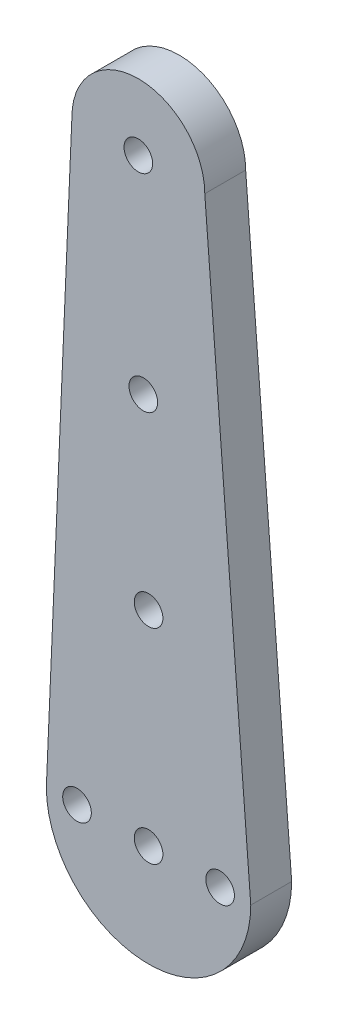
from build123d import *

# Parameters (mm, degrees)
SKETCH1_R           = 1.4
BOSS_EXTRUDE1_DEPTH = 4


with BuildPart() as part:
    # Sketch1 → Boss-Extrude1 (new body)
    with BuildSketch(Plane.XY):
        with BuildLine():
            ThreePointArc((-0.000688459, 65.016091721), (-6.500688459, 71.516091721), (-13.000688459, 65.016091721))
            Line((-13.000688459, 65.016091721), (-15.463628279, 7.853451097))
            Line((-15.463628279, 7.853451097), (-15.500688459, 6.993317296))
            ThreePointArc((-15.500688459, 6.993317296), (-5.500688459, -3.006682704), (4.499311541, 6.993317296))
            Line((4.499311541, 6.993317296), (4.379732895, 8.535158357))
            Line((4.379732895, 8.535158357), (-0.000688459, 65.016091721))
        make_face()
        with Locations((-12.500688459, 6.993317296)):
            Circle(SKETCH1_R, mode=Mode.SUBTRACT)
        with Locations((-5.500688459, 6.993317296)):
            Circle(SKETCH1_R, mode=Mode.SUBTRACT)
        with Locations((1.499311541, 6.993317296)):
            Circle(SKETCH1_R, mode=Mode.SUBTRACT)
        with Locations((-5.500688459, 26.993317296)):
            Circle(SKETCH1_R, mode=Mode.SUBTRACT)
        with Locations((-6.012756351, 45.016091721)):
            Circle(SKETCH1_R, mode=Mode.SUBTRACT)
        with Locations((-6.500688459, 65.016091721)):
            Circle(SKETCH1_R, mode=Mode.SUBTRACT)
    extrude(amount=BOSS_EXTRUDE1_DEPTH)


solid = part.part
